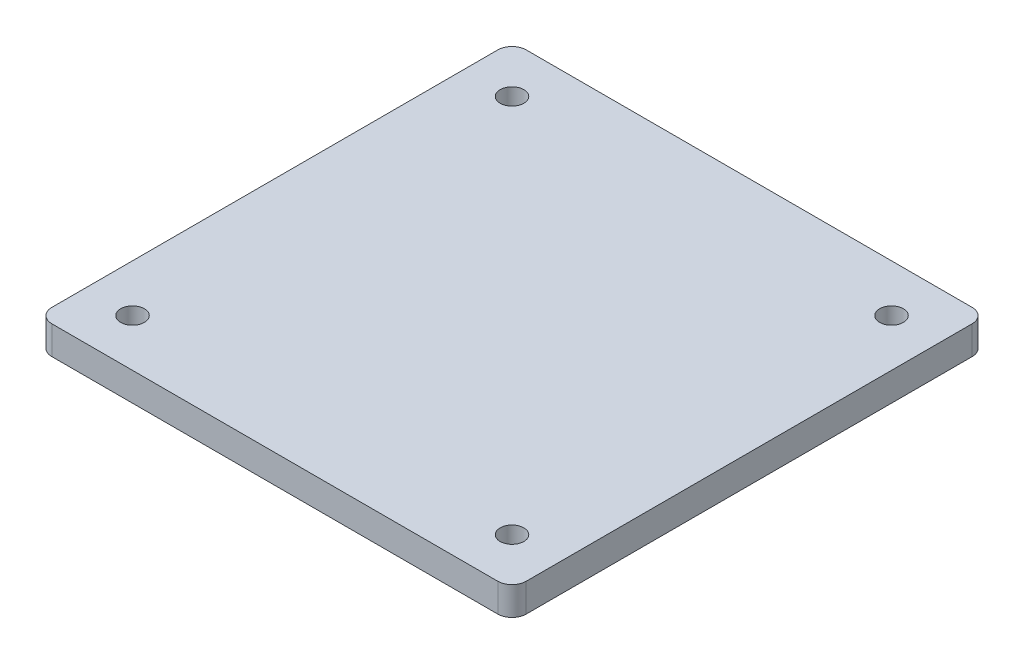
from build123d import *

# Parameters (mm, degrees)
SKETCH1_W           = 100
SKETCH1_H           = 100
SKETCH1_R           = 2.5
BOSS_EXTRUDE1_DEPTH = 6
FILLET1_R           = 3
SCALE1_SCALE        = 7.5


with BuildPart() as part:
    # Sketch1 → Boss-Extrude1 (new body)
    with BuildSketch(Plane(origin=(0, 0, 0), x_dir=(1, 0, 0), z_dir=(0, 1, 0))):
        with Locations((40, -40)):
            Rectangle(SKETCH1_W, SKETCH1_H)
        Circle(SKETCH1_R, mode=Mode.SUBTRACT)
        with Locations((80, 0)):
            Circle(SKETCH1_R, mode=Mode.SUBTRACT)
        with Locations((80, -80)):
            Circle(SKETCH1_R, mode=Mode.SUBTRACT)
        with Locations((0, -80)):
            Circle(SKETCH1_R, mode=Mode.SUBTRACT)
    extrude(amount=BOSS_EXTRUDE1_DEPTH)

    # Fillet1
    fillet1_edges = [part.edges().sort_by_distance(p)[0] for p in [
        (-10, 3, -10),
        (90, 3, -10),
        (90, 3, 90),
        (-10, 3, 90),
    ]]
    fillet(fillet1_edges, radius=FILLET1_R)


with BuildPart() as part_1:
    # Scale1: scaled about (40, 3, 40)
    add(part.part.scale(SCALE1_SCALE).moved(Location((-260, -19.5, -260))))


solid = part_1.part
